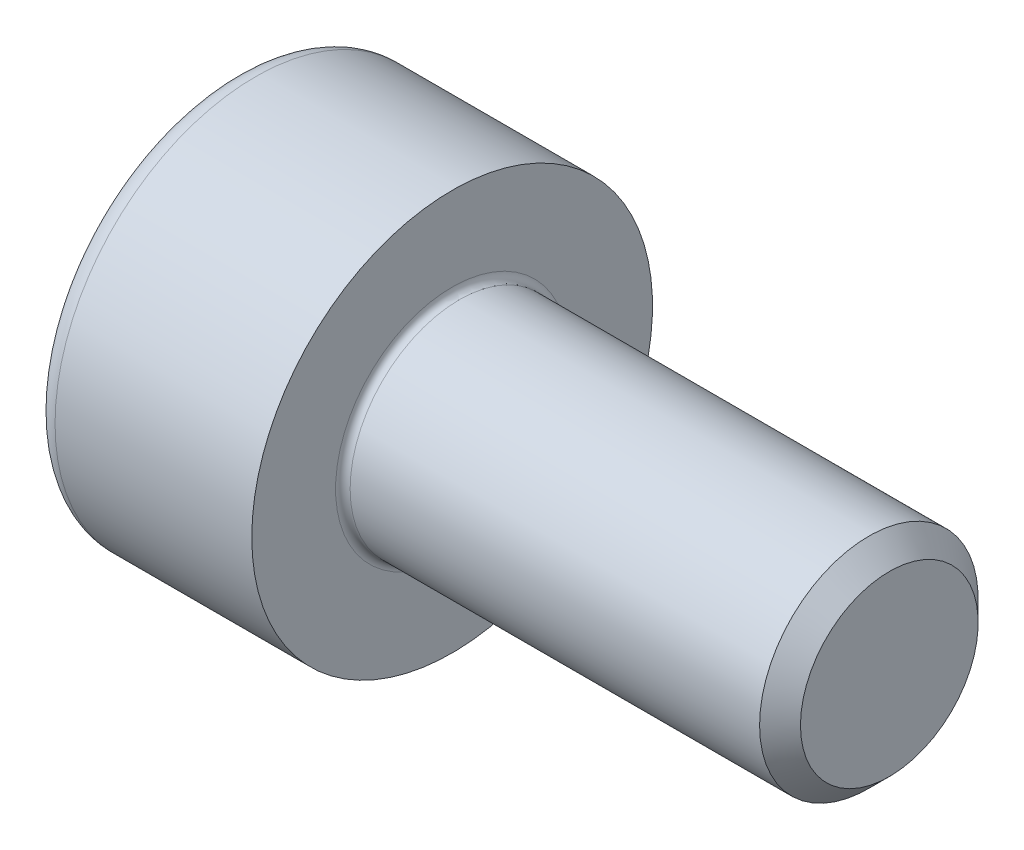
from build123d import *

# Parameters (mm, degrees)
FILLET1_R   = 0.1
FILLET2_R   = 0.3
HEX_2_DEPTH = 1.3


with BuildPart() as part:
    # BodySke → Base-Revolve (revolve)
    with BuildSketch(Plane.XY):
        Polygon((0, 0), (0, 2.75), (3, 2.75), (3, 1.5), (8.7195, 1.5), (9, 1.2195), (9, 0), align=None)
    revolve(axis=Axis((-31.75, 0, 0), (1, 0, 0)))

    # Fillet1
    fillet1_edges = [part.edges().sort_by_distance(p)[0] for p in [
        (3, -1.5, 0),
    ]]
    fillet(fillet1_edges, radius=FILLET1_R)

    # Fillet2
    fillet2_edges = [part.edges().sort_by_distance(p)[0] for p in [
        (0, -2.75, 0),
    ]]
    fillet(fillet2_edges, radius=FILLET2_R)

    # Sketch2 → Hex-PreBroach (revolve, cut)
    with BuildSketch(Plane.XY):
        Polygon((0, 1.26), (1.3, 1.26), (2.027461339, 0), (0, 0), align=None)
    revolve(axis=Axis((0, 0, 0), (1, 0, 0)), mode=Mode.SUBTRACT)

    # Sketch3 → Hex 2 (cut)
    with BuildSketch(Plane(origin=(0, 0, 0), x_dir=(0, 0.5, 0.866025404), z_dir=(-1, 0, 0))):
        Polygon((0.727461339, 1.26), (-0.727461339, 1.26), (-1.454922678, 0), (-0.727461339, -1.26), (0.727461339, -1.26), (1.454922678, 0), align=None)
    extrude(amount=-HEX_2_DEPTH, mode=Mode.SUBTRACT)


solid = part.part
